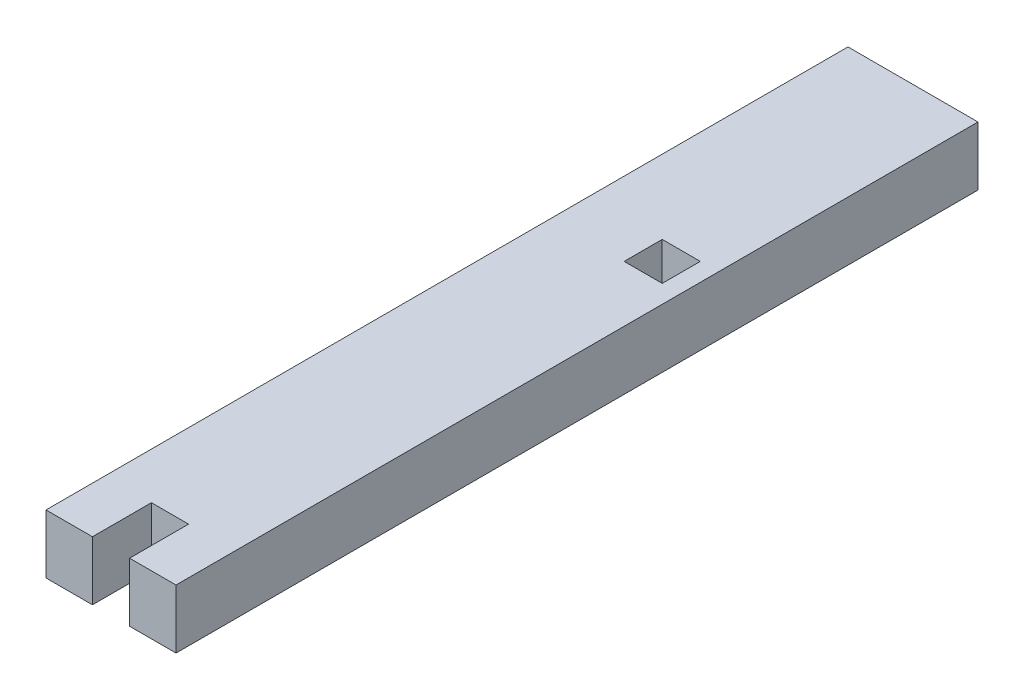
from build123d import *

# Parameters (mm, degrees)
SKETCH1_W           = 2.05
SKETCH1_H           = 2.05
BOSS_EXTRUDE1_DEPTH = 3.175


with BuildPart() as part:
    # Sketch1 → Boss-Extrude1 (new body)
    with BuildSketch(Plane(origin=(0, 0, 0), x_dir=(1, 0, 0), z_dir=(0, 1, 0))):
        Polygon((1, -21.587500005), (3.5, -21.587500005), (3.5, 21.587500005), (-3.5, 21.587500005), (-3.5, -14.587500005), (-3.5, -17.087500005), (-3.5, -19.087500005), (-3.5, -21.587500005), (-1, -21.587500005), (-1, -18.412500005), (1, -18.412500005), align=None)
        with Locations((1.5, 6.587500005)):
            Rectangle(SKETCH1_W, SKETCH1_H, mode=Mode.SUBTRACT)
    extrude(amount=BOSS_EXTRUDE1_DEPTH)


solid = part.part
